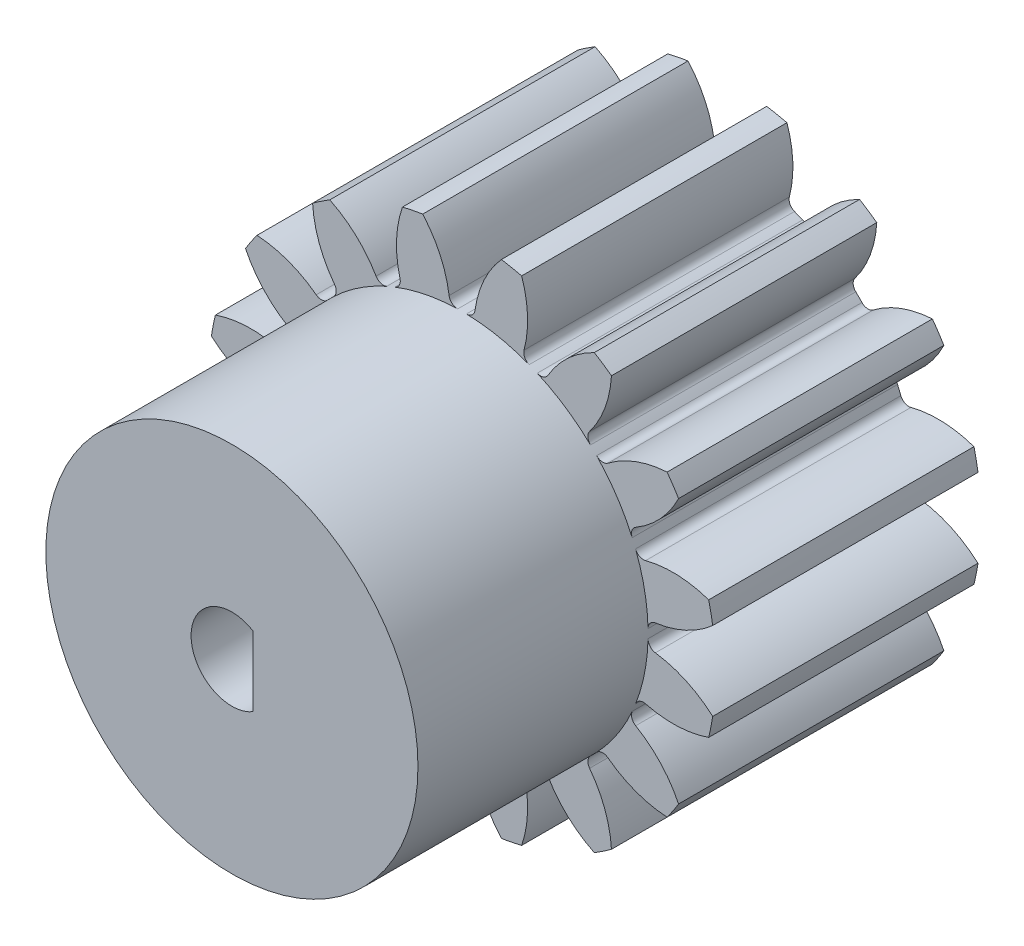
from build123d import *
from build123d.topology import SkipClean

# Parameters (mm, degrees)
SKETCH1_R                = 7.1442
BOSS_EXTRUDE2_DEPTH      = 7.47
CUT_EXTRUDE1_DEPTH       = 13.565034313
FILLET1_R                = 0.23814
CIRPATTERN2_COUNT        = 16
FILLET1_OF_CIRPATTERN2_R = 0.23814
BOSS_EXTRUDE3_START      = 13.95
SKETCH1_6_R              = 5.23908
BOSS_EXTRUDE3_DEPTH      = 13.95
CUT_EXTRUDE4_DEPTH       = 18.153112362
CUT_EXTRUDE4_DEPTH_BACK  = 18.153112362


with BuildPart() as part:
    # Sketch1 → Boss-Extrude2 (new body)
    with BuildSketch(Plane.XY):
        Circle(SKETCH1_R)
    extrude(amount=BOSS_EXTRUDE2_DEPTH)

    # Sketch4 → Cut-Extrude1 (cut, symmetric)
    with BuildSketch(Plane.XY.offset(7.47)):
        with BuildLine():
            ThreePointArc((0.342595828, 5.227866424), (0.900436352, 6.797678574), (2.198617219, 7.841815859))
            ThreePointArc((2.198617219, 7.841815859), (0, 8.1442), (-2.198617219, 7.841815859))
            ThreePointArc((-2.198617219, 7.841815859), (-0.900436352, 6.797678574), (-0.342595828, 5.227866424))
            ThreePointArc((-0.342595828, 5.227866424), (0, 5.23908), (0.342595828, 5.227866424))
        make_face()
    cut_extrude1 = extrude(amount=CUT_EXTRUDE1_DEPTH, both=True, mode=Mode.SUBTRACT)

    # Fillet1
    fillet1_edges = [part.edges().sort_by_distance(p)[0] for p in [
        (-0.342595828, 5.227866424, 3.735),
        (0.342595828, 5.227866424, 3.735),
    ]]
    fillet(fillet1_edges, radius=FILLET1_R)

    # CirPattern2: Cut-Extrude1 ×16 about axis
    cirpattern2_axis = Axis((0, 0, 7.47), (0, 0, -1))
    for i in range(1, CIRPATTERN2_COUNT):
        add(cut_extrude1.rotate(cirpattern2_axis, i * 360 / CIRPATTERN2_COUNT), mode=Mode.SUBTRACT)

    # Fillet1 of CirPattern2
    fillet1_of_cirpattern2_edges = [part.edges().sort_by_distance(p)[0] for p in [
        (1.684100594, 4.961024535, 3.735),
        (2.31713514, 4.69881304, 3.735),
        (3.454407967, 3.938911632, 3.735),
        (3.938911632, 3.454407967, 3.735),
        (4.69881304, 2.31713514, 3.735),
        (4.961024535, 1.684100594, 3.735),
        (5.227866424, 0.342595828, 3.735),
        (5.227866424, -0.342595828, 3.735),
        (4.961024535, -1.684100594, 3.735),
        (4.69881304, -2.31713514, 3.735),
        (3.938911632, -3.454407967, 3.735),
        (3.454407967, -3.938911632, 3.735),
        (2.31713514, -4.69881304, 3.735),
        (1.684100594, -4.961024535, 3.735),
        (0.342595828, -5.227866424, 3.735),
        (-0.342595828, -5.227866424, 3.735),
        (-1.684100594, -4.961024535, 3.735),
        (-2.31713514, -4.69881304, 3.735),
        (-3.454407967, -3.938911632, 3.735),
        (-3.938911632, -3.454407967, 3.735),
        (-4.69881304, -2.31713514, 3.735),
        (-4.961024535, -1.684100594, 3.735),
        (-5.227866424, -0.342595828, 3.735),
        (-5.227866424, 0.342595828, 3.735),
        (-4.961024535, 1.684100594, 3.735),
        (-4.69881304, 2.31713514, 3.735),
        (-3.938911632, 3.454407967, 3.735),
        (-3.454407967, 3.938911632, 3.735),
        (-2.31713514, 4.69881304, 3.735),
        (-1.684100594, 4.961024535, 3.735),
    ]]
    fillet(fillet1_of_cirpattern2_edges, radius=FILLET1_OF_CIRPATTERN2_R)

    # Sketch1_6 → Boss-Extrude3 (add)
    with SkipClean():  # the faces are left unmerged after this step: merging them gives an invalid solid
        with BuildSketch(Plane.XY.offset(BOSS_EXTRUDE3_START)):
            Circle(SKETCH1_6_R)
        extrude(amount=-BOSS_EXTRUDE3_DEPTH)

    # Sketch1_5 → Cut-Extrude4 (cut, two sides: drawn at the far end of the back side and taken through both)
    with SkipClean():  # the faces are left unmerged after this step: merging them gives an invalid solid
        with BuildSketch(Plane.XY.offset(-CUT_EXTRUDE4_DEPTH_BACK)):
            with BuildLine():
                ThreePointArc((0.6, 0.981070844), (-1.15, 0), (0.6, -0.981070844))
                Line((0.6, -0.981070844), (0.6, 0.981070844))
            make_face()
        extrude(amount=CUT_EXTRUDE4_DEPTH + CUT_EXTRUDE4_DEPTH_BACK, mode=Mode.SUBTRACT)


solid = part.part
